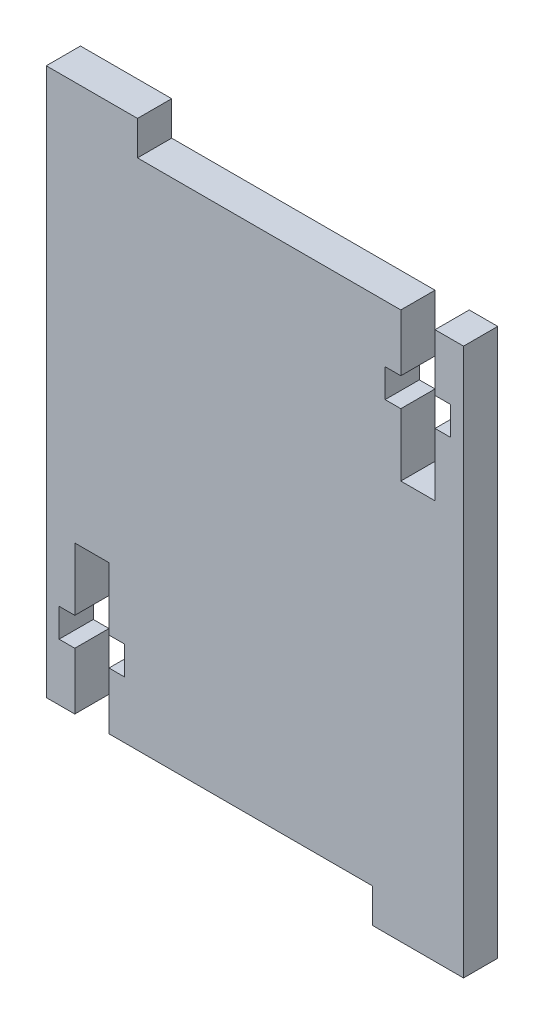
from build123d import *

# Parameters (mm, degrees)
RESSALTO_EXTRUS_O1_DEPTH = 3


with BuildPart() as part:
    # Esboço1 → Ressalto-extrusão1 (new body)
    with BuildSketch(Plane.XY):
        Polygon((-23.190164426, 33.65253981), (-23.190164426, 30.65253981), (-0.090164426, 30.65253981), (-0.090164426, 25.65253981), (-1.465164426, 25.65253981), (-1.465164426, 23.15253981), (-0.090164426, 23.15253981), (-0.090164426, 17.65253981), (2.909835574, 17.65253981), (2.909835574, 23.15253981), (4.284835574, 23.15253981), (4.284835574, 25.65253981), (2.909835574, 25.65253981), (2.909835574, 30.65253981), (5.409835574, 30.65253981), (5.409835574, -14.34746019), (5.409835574, -17.34746019), (-2.590164426, -17.34746019), (-2.590164426, -14.34746019), (-25.690164426, -14.34746019), (-25.690164426, -9.34746019), (-24.315164426, -9.34746019), (-24.315164426, -6.84746019), (-25.690164426, -6.84746019), (-25.690164426, -1.34746019), (-28.690164426, -1.34746019), (-28.690164426, -6.84746019), (-30.065164426, -6.84746019), (-30.065164426, -9.34746019), (-28.690164426, -9.34746019), (-28.690164426, -14.34746019), (-31.190164426, -14.34746019), (-31.190164426, 30.65253981), (-31.190164426, 33.65253981), align=None)
    extrude(amount=RESSALTO_EXTRUS_O1_DEPTH)


solid = part.part
